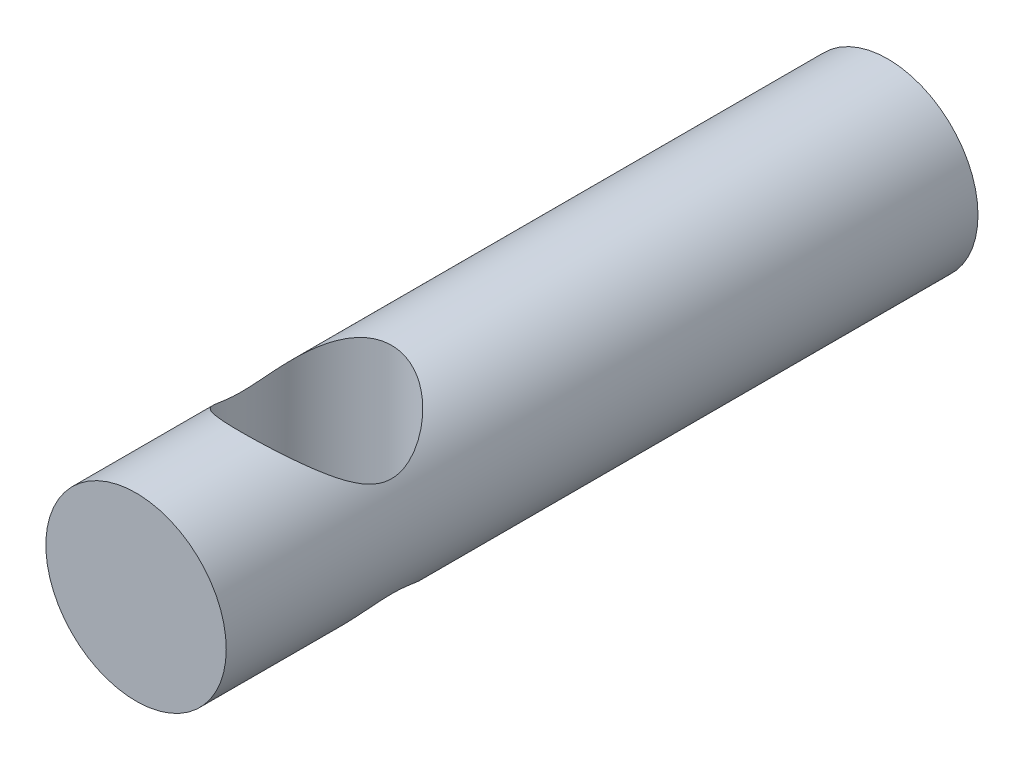
from build123d import *

# Parameters (mm, degrees)
SKETCH1_R               = 6
BOSS_EXTRUDE1_DEPTH     = 50
SKETCH2_R               = 5
CUT_EXTRUDE1_DEPTH      = 7
CUT_EXTRUDE1_DEPTH_BACK = 7


with BuildPart() as part:
    # Sketch1 → Boss-Extrude1 (new body)
    with BuildSketch(Plane.XY):
        Circle(SKETCH1_R)
    extrude(amount=BOSS_EXTRUDE1_DEPTH)

    # Sketch2 → Cut-Extrude1 (cut, two sides)
    with BuildSketch(Plane(origin=(0, 0, 0), x_dir=(1, 0, 0), z_dir=(0, 1, 0))) as cut_extrude1_sk:
        with Locations((0, -38)):
            Circle(SKETCH2_R)
    extrude(amount=CUT_EXTRUDE1_DEPTH, mode=Mode.SUBTRACT)
    extrude(cut_extrude1_sk.sketch, amount=-CUT_EXTRUDE1_DEPTH_BACK, mode=Mode.SUBTRACT)


solid = part.part
